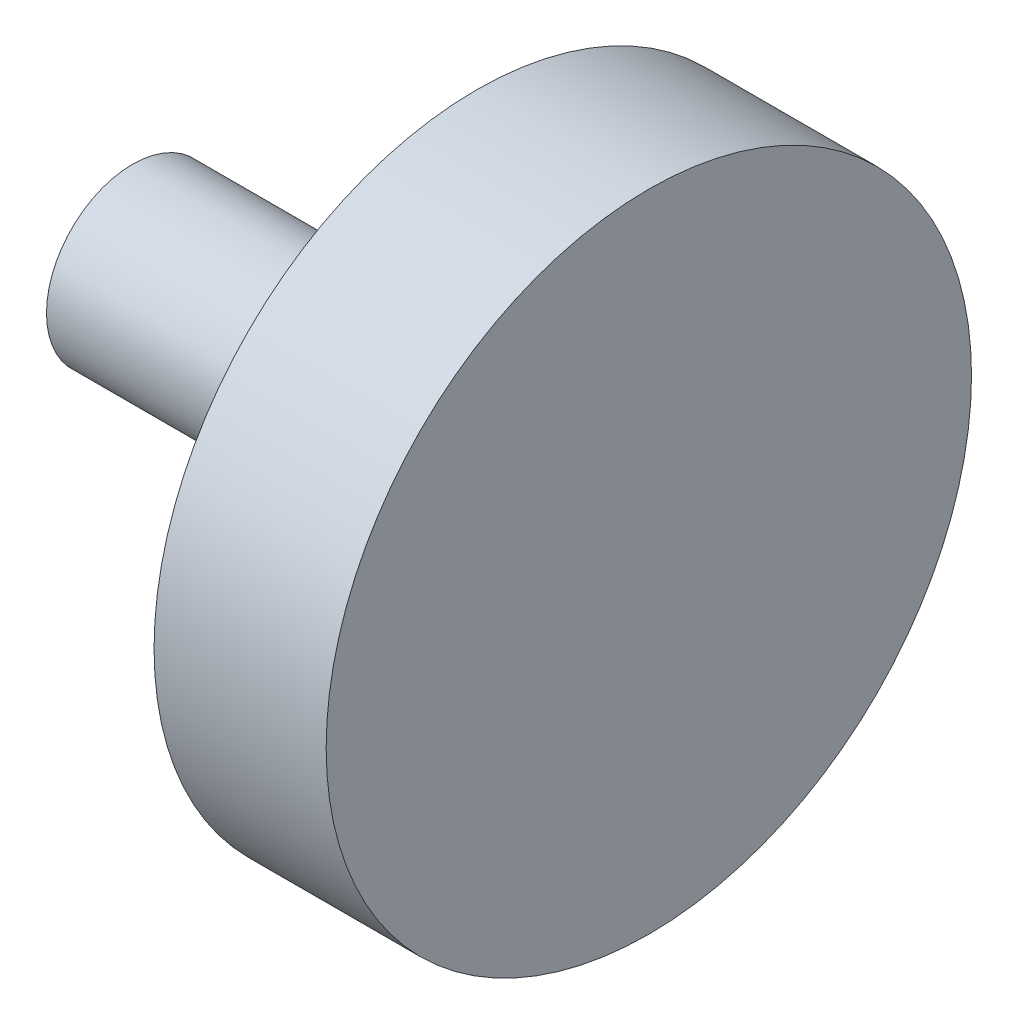
from build123d import *

# Parameters (mm, degrees)
SKETCH1_R           = 7.5
BOSS_EXTRUDE1_DEPTH = 4
SKETCH2_R           = 2
BOSS_EXTRUDE3_DEPTH = 8


with BuildPart() as part:
    # Sketch1 → Boss-Extrude1 (new body)
    with BuildSketch(Plane(origin=(0, 0, 0), x_dir=(0, 0, -1), z_dir=(1, 0, 0))):
        Circle(SKETCH1_R)
    extrude(amount=BOSS_EXTRUDE1_DEPTH)

    # Sketch2 → Boss-Extrude3 (add)
    with BuildSketch(Plane.ZY):
        Circle(SKETCH2_R)
    extrude(amount=BOSS_EXTRUDE3_DEPTH)


solid = part.part
